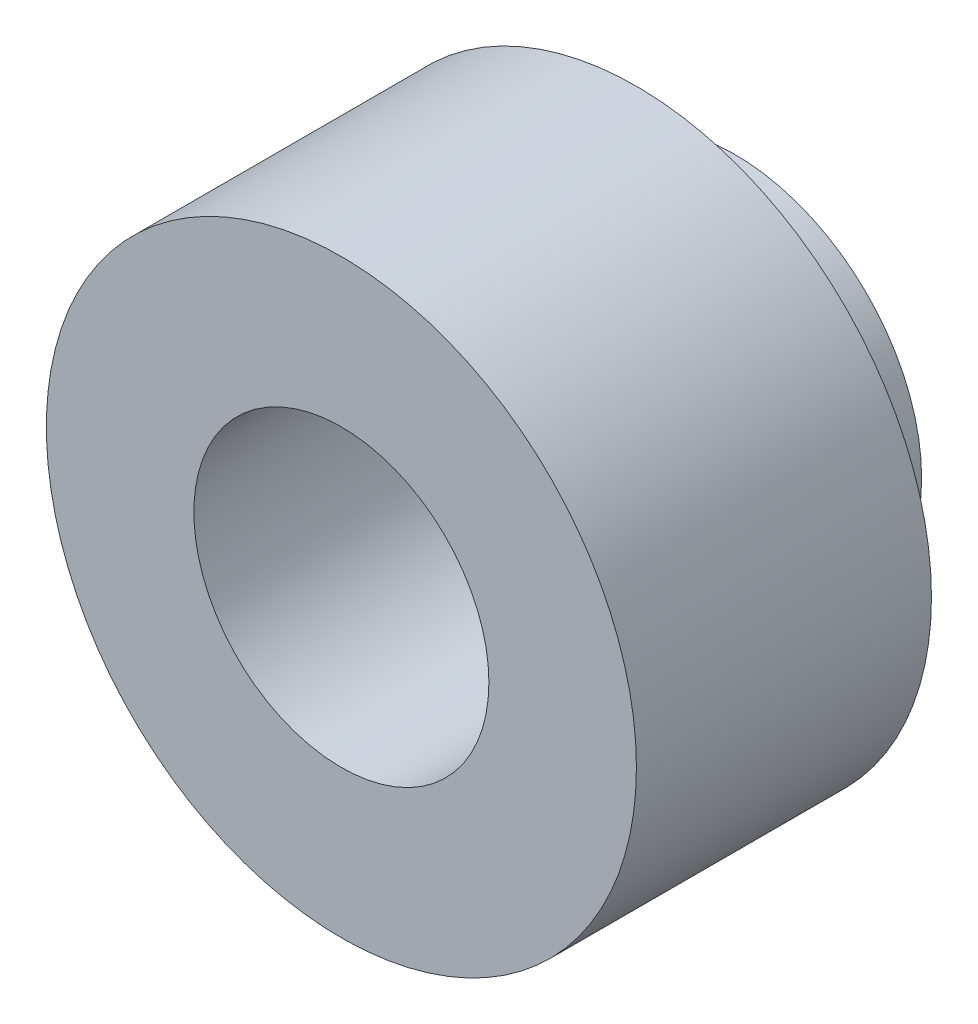
from build123d import *


with BuildPart() as part:
    # Sketch1 → Revolve1 (revolve)
    with BuildSketch(Plane(origin=(0, 0, 0), x_dir=(1, 0, 0), z_dir=(0, 1, 0))):
        Polygon((2.375, 5), (2.375, 3.75), (3.75, 3.75), (3.75, 0), (1.875, 0), (1.875, 5), align=None)
    revolve(axis=Axis((0, 0, 0), (0, 0, -1)))


solid = part.part
